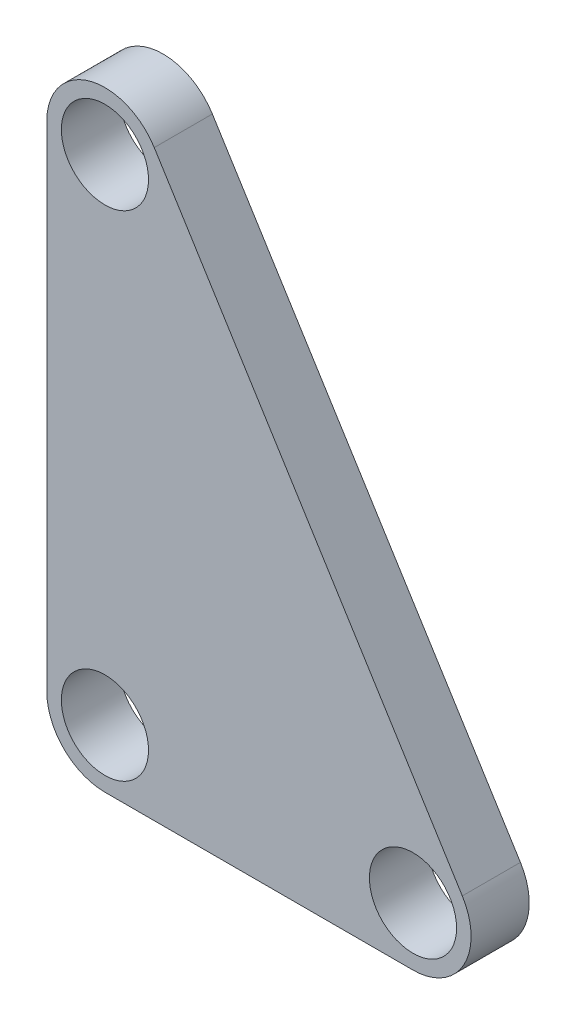
from build123d import *

# Parameters (mm, degrees)
SKETCH1_R           = 0.75
BOSS_EXTRUDE1_DEPTH = 1


with BuildPart() as part:
    # Sketch1 → Boss-Extrude1 (new body)
    with BuildSketch(Plane.XY):
        with BuildLine():
            Line((0, 9.5), (0, 1))
            ThreePointArc((0, 1), (0.292893219, 0.292893219), (1, 0))
            Line((1, 0), (6.3, 0))
            ThreePointArc((6.3, 0), (7.174385868, 0.514768762), (7.148558674, 1.529101291))
            Line((7.148558674, 1.529101291), (1.848558674, 10.029101291))
            ThreePointArc((1.848558674, 10.029101291), (0.724826123, 10.461394475), (0, 9.5))
        make_face()
        with Locations((1, 1)):
            Circle(SKETCH1_R, mode=Mode.SUBTRACT)
        with Locations((1, 9.5)):
            Circle(SKETCH1_R, mode=Mode.SUBTRACT)
        with Locations((6.3, 1)):
            Circle(SKETCH1_R, mode=Mode.SUBTRACT)
    extrude(amount=BOSS_EXTRUDE1_DEPTH)


solid = part.part
